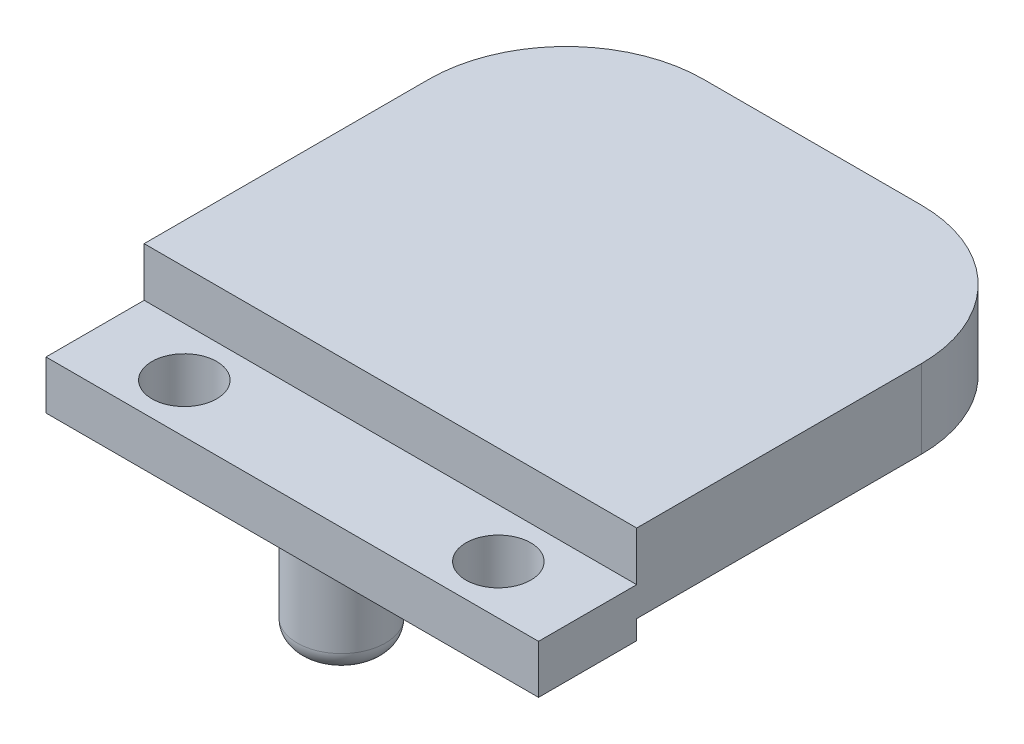
from build123d import *

# Parameters (mm, degrees)
SKETCH4_W                = 12.46
SKETCH4_H                = 17.25
BOSS_EXTRUDE3_DEPTH      = 6
SKETCH8_R                = 12.546781182
SKETCH8_R_2              = 11.15
BOSS_EXTRUDE6_DEPTH      = 8.3
BOSS_EXTRUDE6_DEPTH_BACK = 17.25
BOSS_EXTRUDE4_DEPTH      = 17.25
SKETCH6_R                = 0.75
CUT_EXTRUDE1_DEPTH       = 5
CHAMFER1_SIZE            = 0.5
CHAMFER1_SIZE2           = 0.866025404
SKETCH10_W               = 12.46
SKETCH10_H               = 23.7
CUT_EXTRUDE3_DEPTH       = 17.25
BOSS_EXTRUDE7_DEPTH      = 8.3
BOSS_EXTRUDE9_DEPTH      = 10
SKETCH20_R               = 11.15
SKETCH20_R_2             = 7.15
BOSS_EXTRUDE11_DEPTH     = 8.3
SKETCH21_R               = 10.15
SKETCH21_R_2             = 7.15
CUT_EXTRUDE7_DEPTH       = 1.3
SKETCH11_W               = 10
SKETCH11_H               = 2
CUT_EXTRUDE4_DEPTH       = 23.7
CUT_EXTRUDE8_REACH       = 37.55
SKETCH24_W               = 12.46
SKETCH24_H               = 6
BOSS_EXTRUDE10_DEPTH     = 25.093562
SKETCH18_W               = 21.5
SKETCH18_H               = 12.438292938
CUT_EXTRUDE5_DEPTH       = 2
SKETCH19_R               = 3.5
CUT_EXTRUDE6_DEPTH       = 43.5
CUT_EXTRUDE6_DEPTH_BACK  = 3
FILLET1_R                = 7
SKETCH22_R               = 6.5
BOSS_EXTRUDE12_DEPTH     = 5
SKETCH23_R               = 6.075
BOSS_EXTRUDE13_DEPTH     = 5
FILLET2_R                = 1
BOSS_EXTRUDE15_DEPTH     = 2
CUT_EXTRUDE9_REACH       = 46.5
SKETCH26_R               = 0.75
CUT_EXTRUDE10_DEPTH      = 26.093562364
SKETCH28_R               = 1.65
CUT_EXTRUDE11_DEPTH      = 5.975
SKETCH29_R               = 2.25
BOSS_EXTRUDE16_DEPTH     = 5
FILLET3_R                = 1
SKETCH30_W               = 5
SKETCH30_H               = 2.5
CUT_EXTRUDE12_DEPTH      = 26.093562364


with BuildPart() as part:
    # Sketch4 → Boss-Extrude3 (new body)
    with BuildSketch(Plane.XY):
        with Locations((0, -1.35)):
            Rectangle(SKETCH4_W, SKETCH4_H)
    extrude(amount=BOSS_EXTRUDE3_DEPTH)



with BuildPart() as body_2:
    # Sketch8 → Boss-Extrude6 (new body, two sides)
    with BuildSketch(Plane(origin=(0, -9.975, 0), x_dir=(-1, 0, 0), z_dir=(0, -1, 0))) as boss_extrude6_sk:
        with Locations((0, -23.55)):
            Circle(SKETCH8_R)
        with Locations((0, -23.55)):
            Circle(SKETCH8_R_2, mode=Mode.SUBTRACT)
    extrude(amount=BOSS_EXTRUDE6_DEPTH)
    extrude(boss_extrude6_sk.sketch, amount=-BOSS_EXTRUDE6_DEPTH_BACK)


with BuildPart() as part_1:
    add(part.part)

    add(body_2.part)  # Boss-Extrude4 merges body 2
    # Sketch5 → Boss-Extrude4 (add)
    with BuildSketch(Plane(origin=(0, 7.275, 0), x_dir=(1, 0, 0), z_dir=(0, 1, 0))):
        with BuildLine():
            Line((12.546781182, -23.55), (12.546781182, 0))
            Line((12.546781182, 0), (6.23, 0))
            Line((6.23, 0), (6.23, -29.7))
            Line((6.23, -29.7), (-6.23, -29.7))
            Line((-6.23, -29.7), (-6.23, 0))
            Line((-6.23, 0), (-12.546781182, 0))
            Line((-12.546781182, 0), (-12.546781182, -23.55))
            ThreePointArc((-12.546781182, -23.55), (0, -36.096781182), (12.546781182, -23.55))
        make_face()
    extrude(amount=-BOSS_EXTRUDE4_DEPTH)

    # Sketch6 → Cut-Extrude1 (cut)
    with BuildSketch(Plane(origin=(0, 7.275, 0), x_dir=(1, 0, 0), z_dir=(0, 1, 0))):
        with Locations((0, -3.6)):
            Circle(SKETCH6_R)
        with Locations((0, -32.1)):
            Circle(SKETCH6_R)
    extrude(amount=-CUT_EXTRUDE1_DEPTH, mode=Mode.SUBTRACT)

    # Chamfer1
    chamfer1_edges = [part_1.edges().sort_by_distance(p)[0] for p in [
        (-0.75, 7.275, 3.6),
        (-0.75, 7.275, 32.1),
    ]]
    chamfer1_side = [part_1.faces().sort_by_distance(p)[0] for p in [
        (0, 7.275, 35.657160381),
    ]]
    chamfer(chamfer1_edges, length=CHAMFER1_SIZE, length2=CHAMFER1_SIZE2, reference=chamfer1_side[0])

    # Sketch10 → Cut-Extrude3 (cut)
    with BuildSketch(Plane(origin=(0, 7.275, 0), x_dir=(1, 0, 0), z_dir=(0, 1, 0))):
        with Locations((0, -17.85)):
            Rectangle(SKETCH10_W, SKETCH10_H)
    extrude(amount=-CUT_EXTRUDE3_DEPTH, mode=Mode.SUBTRACT)

    # Sketch13 → Boss-Extrude7 (add)
    with BuildSketch(Plane.XZ.offset(18.275)):
        with BuildLine():
            Line((-12.546781182, 23.55), (-12.546781182, 0))
            Line((-12.546781182, 0), (12.546781182, 0))
            Line((12.546781182, 0), (12.546781182, 23.55))
            ThreePointArc((12.546781182, 23.55), (0, 11.003218818), (-12.546781182, 23.55))
        make_face()
    extrude(amount=-BOSS_EXTRUDE7_DEPTH)

    # Sketch15 → Boss-Extrude9 (add)
    with BuildSketch(Plane(origin=(0, 7.275, 0), x_dir=(1, 0, 0), z_dir=(0, 1, 0))):
        with BuildLine():
            Line((-12.546781182, 0), (12.546781182, 0))
            Line((12.546781182, 0), (12.546781182, -23.55))
            ThreePointArc((12.546781182, -23.55), (0, -36.096781182), (-12.546781182, -23.55))
            Line((-12.546781182, -23.55), (-12.546781182, 0))
        make_face()
        with BuildLine():
            Line((-6.23, -0.8), (6.23, -0.8))
            Line((6.23, -0.8), (6.23, -33))
            ThreePointArc((6.23, -33), (5.790660172, -34.060660172), (4.73, -34.5))
            Line((4.73, -34.5), (-4.73, -34.5))
            ThreePointArc((-4.73, -34.5), (-5.790660172, -34.060660172), (-6.23, -33))
            Line((-6.23, -33), (-6.23, -0.8))
        make_face(mode=Mode.SUBTRACT)
    extrude(amount=BOSS_EXTRUDE9_DEPTH)

    # Sketch20 → Boss-Extrude11 (add)
    with BuildSketch(Plane.XZ.offset(18.275)):
        with Locations((0, 23.55)):
            Circle(SKETCH20_R)
        with Locations((0, 23.55)):
            Circle(SKETCH20_R_2, mode=Mode.SUBTRACT)
    extrude(amount=-BOSS_EXTRUDE11_DEPTH)

    # Sketch21 → Cut-Extrude7 (cut)
    with BuildSketch(Plane.XZ.offset(18.275)):
        with Locations((0, 23.55)):
            Circle(SKETCH21_R)
        with Locations((0, 23.55)):
            Circle(SKETCH21_R_2, mode=Mode.SUBTRACT)
    extrude(amount=-CUT_EXTRUDE7_DEPTH, mode=Mode.SUBTRACT)

    # Sketch11 → Cut-Extrude4 (cut)
    with BuildSketch(Plane.XY.offset(29.7)):
        with Locations((0, -10.975)):
            Rectangle(SKETCH11_W, SKETCH11_H)
    extrude(amount=-CUT_EXTRUDE4_DEPTH, mode=Mode.SUBTRACT)

    # Sketch24 → Cut-Extrude8 (cut, up to next)
    with BuildSketch(Plane.XZ.offset(18.275), mode=Mode.PRIVATE) as cut_extrude8_sk1:
        with Locations((0, 9)):
            Rectangle(SKETCH24_W, SKETCH24_H)
    cut_extrude8_tool1 = extrude(cut_extrude8_sk1.sketch, amount=-CUT_EXTRUDE8_REACH, mode=Mode.PRIVATE) & part_1.part
    add(cut_extrude8_tool1.solids().sort_by_distance((0, -18.275, 9))[0], mode=Mode.SUBTRACT)

    # Sketch17 → Boss-Extrude10 (add)
    with BuildSketch(Plane(origin=(-12.546781182, 4.728218818, 0), x_dir=(0, -1, 0), z_dir=(1, 0, 0))):
        Polygon((26.978218818, 26.5), (26.978218818, 0), (-17.521781182, 0), (-17.521781182, 26.5), (-13.521781182, 26.5), (-13.521781182, 5), (22.978218818, 5), (22.978218818, 26.5), align=None)
    extrude(amount=BOSS_EXTRUDE10_DEPTH)

    # Sketch18 → Cut-Extrude5 (cut)
    with BuildSketch(Plane.ZX.offset(-18.25)):
        with Locations((-15.75, 0)):
            Rectangle(SKETCH18_W, SKETCH18_H)
    extrude(amount=-CUT_EXTRUDE5_DEPTH, mode=Mode.SUBTRACT)

    # Sketch19 → Cut-Extrude6 (cut, two sides)
    with BuildSketch(Plane.ZX.offset(-20.25)) as cut_extrude6_sk:
        with Locations((-20, 0)):
            Circle(SKETCH19_R)
    extrude(amount=CUT_EXTRUDE6_DEPTH, mode=Mode.SUBTRACT)
    extrude(cut_extrude6_sk.sketch, amount=-CUT_EXTRUDE6_DEPTH_BACK, mode=Mode.SUBTRACT)

    # Fillet1
    fillet1_edges = [part_1.edges().sort_by_distance(p)[0] for p in [
        (12.546780818, -20.25, -26.5),
        (-12.546781182, -20.25, -26.5),
        (-12.546781182, 20.25, -26.5),
        (12.546780818, 20.25, -26.5),
    ]]
    fillet(fillet1_edges, radius=FILLET1_R)

    # Sketch22 → Boss-Extrude12 (add)
    with BuildSketch(Plane(origin=(0, 22.25, 0), x_dir=(1, 0, 0), z_dir=(0, 1, 0))):
        with Locations((0, 20)):
            Circle(SKETCH22_R)
    extrude(amount=-BOSS_EXTRUDE12_DEPTH)

    # Sketch23 → Boss-Extrude13 (add)
    with BuildSketch(Plane.XZ.offset(-17.25)):
        with Locations((0, -20)):
            Circle(SKETCH23_R)
    extrude(amount=BOSS_EXTRUDE13_DEPTH)

    # Fillet2
    fillet2_edges = [part_1.edges().sort_by_distance(p)[0] for p in [
        (-6.075, 12.25, -20),
    ]]
    fillet(fillet2_edges, radius=FILLET2_R)

    # Sketch25 → Boss-Extrude15 (add)
    with BuildSketch(Plane(origin=(0, -20.25, 0), x_dir=(1, 0, 0), z_dir=(0, 1, 0))):
        Polygon((-6.219146469, 5), (-2.5, 5), (-3.1585, 20), (-3.44385, 26.5), (-6.219146469, 26.5), align=None)
        Polygon((6.219146469, 5), (2.5, 5), (3.1585, 20), (3.44385, 26.5), (6.219146469, 26.5), align=None)
    extrude(amount=BOSS_EXTRUDE15_DEPTH)

    # Sketch26 → Cut-Extrude9 (cut, up to next)
    with BuildSketch(Plane(origin=(0, -22.25, 0), x_dir=(-1, 0, 0), z_dir=(0, -1, 0)), mode=Mode.PRIVATE) as cut_extrude9_sk1:
        with Locations((0, 10)):
            Circle(SKETCH26_R)
    cut_extrude9_tool1 = extrude(cut_extrude9_sk1.sketch, amount=-CUT_EXTRUDE9_REACH, mode=Mode.PRIVATE) & part_1.part
    add(cut_extrude9_tool1.solids().sort_by_distance((0, -22.25, -10))[0], mode=Mode.SUBTRACT)

    # Sketch27 → Cut-Extrude10 (cut, through all)
    with BuildSketch(Plane.ZY.offset(12.546781182)):
        Polygon((36.096781182, 17.275), (-10.020668602, 17.275), (-10.020668602, 5.331631915), (-33.329469664, 5.331631915), (-33.329469664, -27.204993615), (36.096781182, -27.204993615), align=None)
    extrude(amount=-CUT_EXTRUDE10_DEPTH, mode=Mode.SUBTRACT)

    # Sketch28 → Cut-Extrude11 (cut, through all)
    with BuildSketch(Plane.XZ.offset(-17.275)):
        with Locations((-8, -2.5)):
            Circle(SKETCH28_R)
        with Locations((8, -2.5)):
            Circle(SKETCH28_R)
    extrude(amount=-CUT_EXTRUDE11_DEPTH, mode=Mode.SUBTRACT)

    # Sketch29 → Boss-Extrude16 (add)
    with BuildSketch(Plane.XZ.offset(-17.275)):
        with Locations((0, -2.5)):
            Circle(SKETCH29_R)
    extrude(amount=BOSS_EXTRUDE16_DEPTH)

    # Fillet3
    fillet3_edges = [part_1.edges().sort_by_distance(p)[0] for p in [
        (-2.25, 12.275, -2.5),
    ]]
    fillet(fillet3_edges, radius=FILLET3_R)

    # Sketch30 → Cut-Extrude12 (cut, through all)
    with BuildSketch(Plane(origin=(12.546781182, 0, 0), x_dir=(0, 0, -1), z_dir=(1, 0, 0))):
        with Locations((2.5, 21)):
            Rectangle(SKETCH30_W, SKETCH30_H)
    extrude(amount=-CUT_EXTRUDE12_DEPTH, mode=Mode.SUBTRACT)


solid = part_1.part
